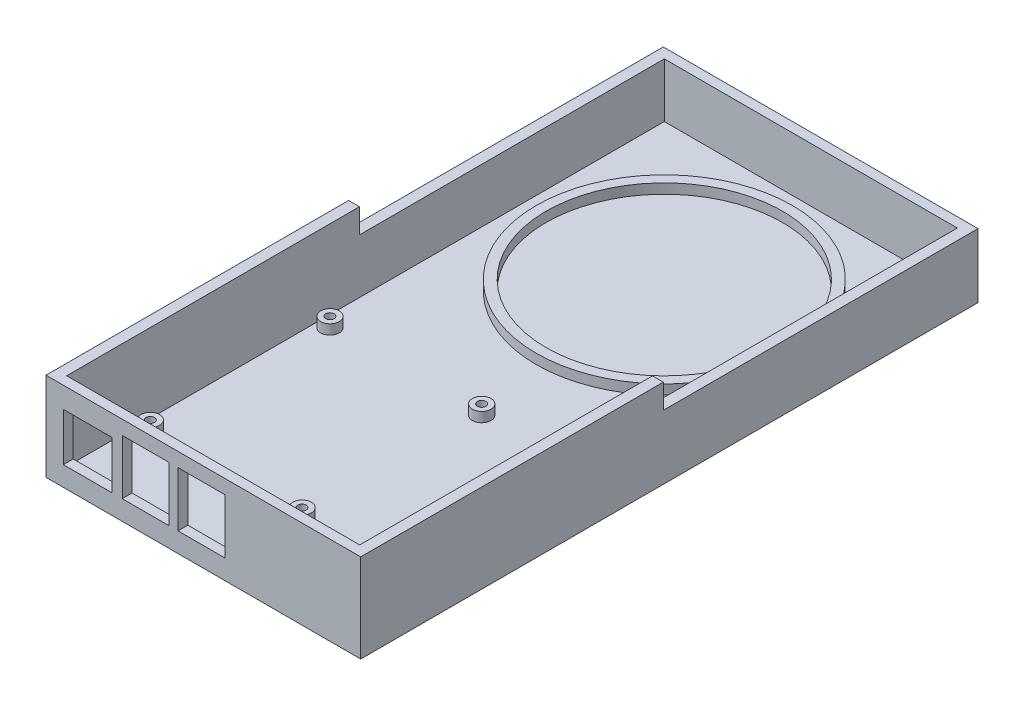
from build123d import *

# Parameters (mm, degrees)
SKETCH2_W           = 101.6
SKETCH2_H           = 3.175
BOSS_EXTRUDE1_DEPTH = 199.3
SKETCH3_W           = 101.6
SKETCH3_H           = 199.3
SKETCH3_W_2         = 94.6
SKETCH3_H_2         = 192.95
BOSS_EXTRUDE2_DEPTH = 25.4
SKETCH5_R           = 41.3385
SKETCH5_R_2         = 38.1635
BOSS_EXTRUDE4_DEPTH = 3.175
SKETCH7_R           = 3
SKETCH7_R_2         = 1.375
BOSS_EXTRUDE5_DEPTH = 3.175
SKETCH8_W           = 15.6845
SKETCH8_H           = 15.4686
SKETCH8_W_2         = 15.113
SKETCH8_H_2         = 17.6911
CUT_EXTRUDE1_DEPTH  = 3.175
SKETCH9_R           = 1.375
CUT_EXTRUDE2_DEPTH  = 3.175
SKETCH10_W          = 101.6
SKETCH10_H          = 101.6
CUT_EXTRUDE3_DEPTH  = 7.874


with BuildPart() as part:
    # Sketch2 → Boss-Extrude1 (new body)
    with BuildSketch(Plane.XY):
        with Locations((50.8, 1.5875)):
            Rectangle(SKETCH2_W, SKETCH2_H)
    extrude(amount=BOSS_EXTRUDE1_DEPTH)

    # Sketch3 → Boss-Extrude2 (add)
    with BuildSketch(Plane(origin=(0, 3.175, 0), x_dir=(1, 0, 0), z_dir=(0, 1, 0))):
        with Locations((50.8, -99.65)):
            Rectangle(SKETCH3_W, SKETCH3_H)
        with Locations((50.8, -99.65)):
            Rectangle(SKETCH3_W_2, SKETCH3_H_2, mode=Mode.SUBTRACT)
    extrude(amount=BOSS_EXTRUDE2_DEPTH)

    # Sketch5 → Boss-Extrude4 (add)
    with BuildSketch(Plane(origin=(0, 3.175, 0), x_dir=(1, 0, 0), z_dir=(0, 1, 0))):
        with Locations((50.8, -50.475)):
            Circle(SKETCH5_R)
        with Locations((50.8, -50.475)):
            Circle(SKETCH5_R_2, mode=Mode.SUBTRACT)
    extrude(amount=BOSS_EXTRUDE4_DEPTH)

    # Sketch7 → Boss-Extrude5 (add)
    with BuildSketch(Plane(origin=(0, 3.175, 0), x_dir=(1, 0, 0), z_dir=(0, 1, 0))):
        with Locations((7.127, -172.752)):
            Circle(SKETCH7_R)
        with Locations((7.127, -172.752)):
            Circle(SKETCH7_R_2, mode=Mode.SUBTRACT)
        with Locations((7.127, -114.752)):
            Circle(SKETCH7_R)
        with Locations((7.127, -114.752)):
            Circle(SKETCH7_R_2, mode=Mode.SUBTRACT)
        with Locations((56.127, -172.752)):
            Circle(SKETCH7_R)
        with Locations((56.127, -172.752)):
            Circle(SKETCH7_R_2, mode=Mode.SUBTRACT)
        with Locations((56.127, -114.752)):
            Circle(SKETCH7_R)
        with Locations((56.127, -114.752)):
            Circle(SKETCH7_R_2, mode=Mode.SUBTRACT)
    extrude(amount=BOSS_EXTRUDE5_DEPTH)

    # Sketch8 → Cut-Extrude1 (cut)
    with BuildSketch(Plane.XY.offset(199.3)):
        with Locations((13.425, 14.0843)):
            Rectangle(SKETCH8_W, SKETCH8_H)
        with Locations((32.175, 15.19555)):
            Rectangle(SKETCH8_W_2, SKETCH8_H_2)
        with Locations((50.175, 15.19555)):
            Rectangle(SKETCH8_W_2, SKETCH8_H_2)
    extrude(amount=-CUT_EXTRUDE1_DEPTH, mode=Mode.SUBTRACT)

    # Sketch9 → Cut-Extrude2 (cut)
    with BuildSketch(Plane(origin=(0, 3.175, 0), x_dir=(1, 0, 0), z_dir=(0, 1, 0))):
        with Locations((7.127, -114.752)):
            Circle(SKETCH9_R)
        with Locations((56.127, -114.752)):
            Circle(SKETCH9_R)
        with Locations((56.127, -172.752)):
            Circle(SKETCH9_R)
        with Locations((7.127, -172.752)):
            Circle(SKETCH9_R)
    extrude(amount=-CUT_EXTRUDE2_DEPTH, mode=Mode.SUBTRACT)

    # Sketch10 → Cut-Extrude3 (cut)
    with BuildSketch(Plane(origin=(0, 28.575, 0), x_dir=(1, 0, 0), z_dir=(0, 1, 0))):
        with Locations((50.8, -50.8)):
            Rectangle(SKETCH10_W, SKETCH10_H)
    extrude(amount=-CUT_EXTRUDE3_DEPTH, mode=Mode.SUBTRACT)


solid = part.part
